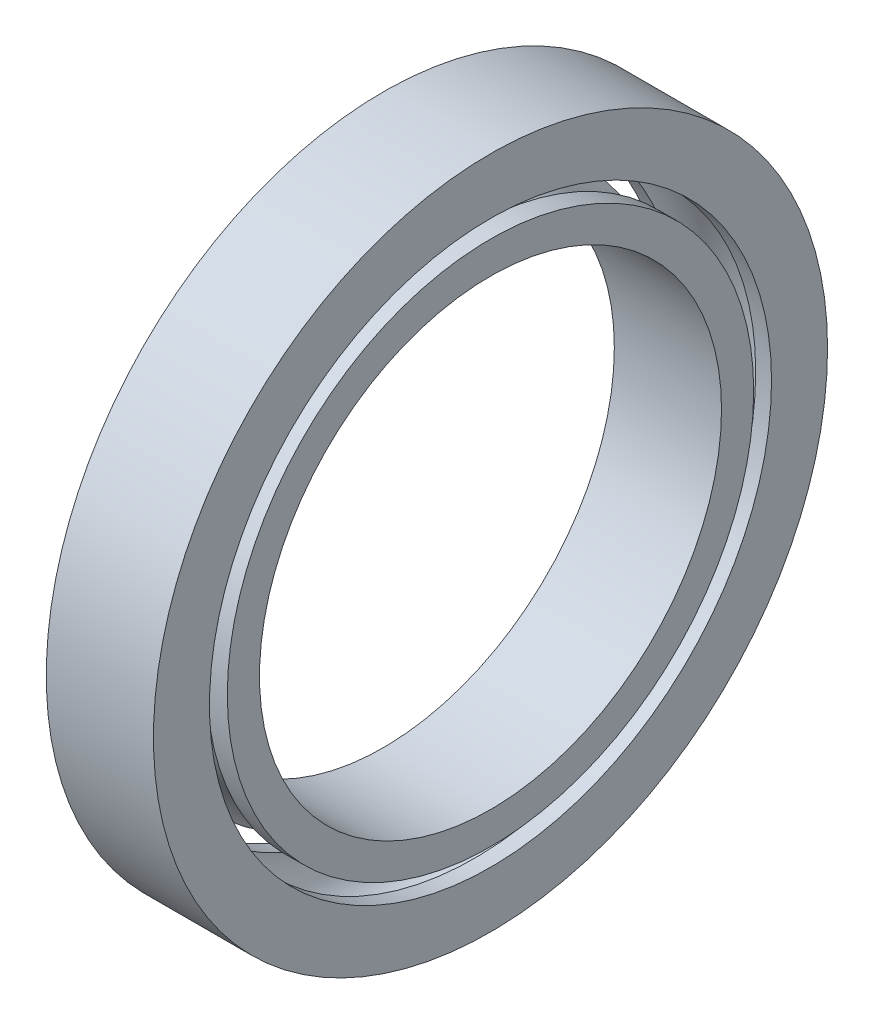
from build123d import *


with BuildPart() as part:
    # Sketch1 → Revolve5 (revolve)
    with BuildSketch(Plane.XY):
        with BuildLine():
            Line((-16.127831396, 120), (-22.884866264, 120))
            Line((-22.884866264, 120), (-22.884866264, 143.921086162))
            Line((-22.884866264, 143.921086162), (22.884866264, 143.921086162))
            Line((22.884866264, 143.921086162), (22.884866264, 120))
            Line((22.884866264, 120), (16.127831396, 120))
            ThreePointArc((16.127831396, 120), (0, 136.127831396), (-16.127831396, 120))
        make_face()
        with BuildLine():
            Line((22.884866264, 98.643368221), (-22.884866264, 98.643368221))
            Line((-22.884866264, 98.643368221), (-22.884866264, 112.385243705))
            Line((-22.884866264, 112.385243705), (-14.216976898, 112.385243705))
            ThreePointArc((-14.216976898, 112.385243705), (0, 103.872168604), (14.216976898, 112.385243705))
            Line((14.216976898, 112.385243705), (22.884866264, 112.385243705))
            Line((22.884866264, 112.385243705), (22.884866264, 98.643368221))
        make_face()
    revolve(axis=Axis((89.103484186, 0, 0), (-1, 0, 0)))


solid = part.part
